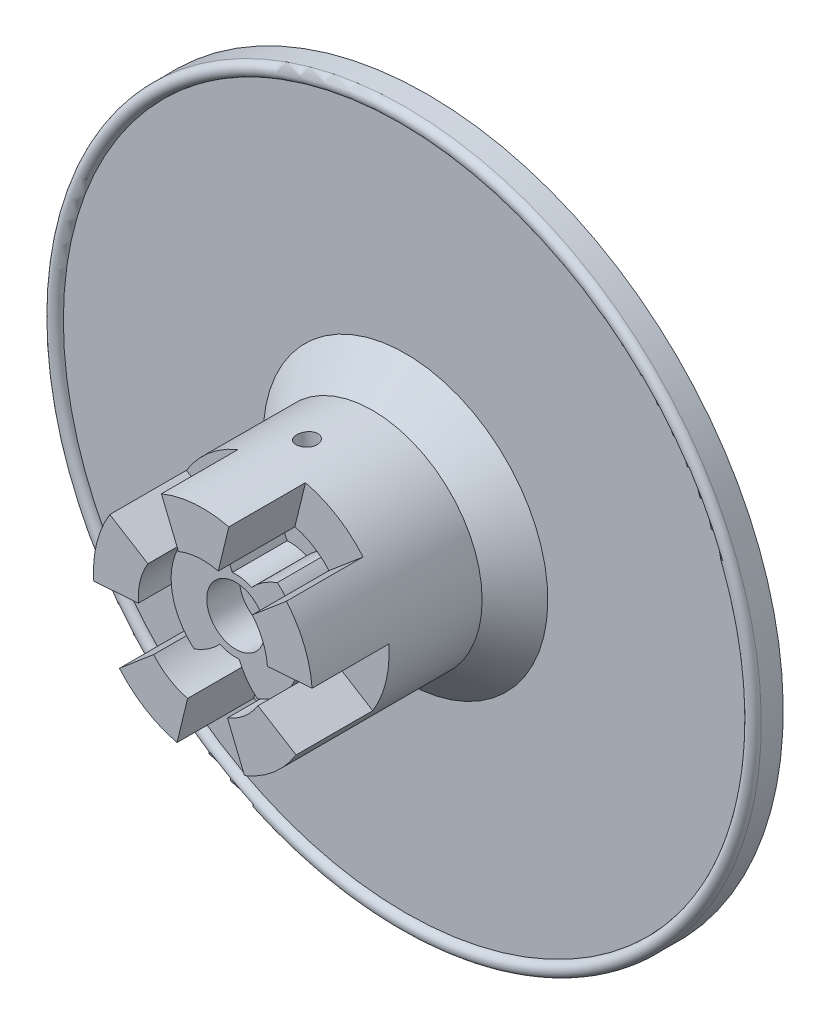
from build123d import *

# Parameters (mm, degrees)
SKETCH11_R                      = 3.3672
CUT_EXTRUDE5_DEPTH              = 3.81
SKETCH11_5_R                    = 3.3672
CUT_EXTRUDE7_DEPTH              = 7.62
CUT_EXTRUDE8_DEPTH              = 10.16
SKETCH13_R                      = 6.35
CUT_EXTRUDE10_DEPTH             = 12.192
CHAMFER1_SIZE                   = 3.81
CHAMFER2_SIZE                   = 3.81
CUT_EXTRUDE11_DEPTH             = 8.89
F_3_32_0_09375_DIAMETER_HOLE1_D = 2.38125


with BuildPart() as part:
    # Sketch2 → Revolve1 (revolve)
    with BuildSketch(Plane(origin=(0, 0, 0), x_dir=(0, 0, -1), z_dir=(1, 0, 0))):
        Polygon((-13.0175, 0), (-13.0175, 9.525), (-13.0175, 12.7), (-9.8425, 12.7), (10.4775, 12.7), (10.4775, 41.275), (13.0175, 41.275), (13.0175, 0), align=None)
    revolve(axis=Axis((0, 0, -13.0175), (0, 0, 1)))

    # Sketch11 → Cut-Extrude5 (cut)
    with BuildSketch(Plane.XY.offset(13.0175)):
        with BuildLine():
            ThreePointArc((-4.819494332, -5.746518457), (-1.340267005, -7.379273972), (2.490906416, -7.074276304))
            ThreePointArc((2.490906416, -7.074276304), (1.265901972, -5.744591723), (0.392647765, -4.16151748))
            ThreePointArc((0.392647765, -4.16151748), (-0.746975478, -4.11271536), (-1.830973459, -3.757650355))
            ThreePointArc((-1.830973459, -3.757650355), (-3.205144168, -4.932534109), (-4.819494332, -5.746518457))
        make_face()
        with BuildLine():
            ThreePointArc((7.5, 0), (6.796918695, 3.17047256), (4.819494332, 5.746518457))
            ThreePointArc((4.819494332, 5.746518457), (3.205144168, 4.932534109), (1.830973459, 3.757650355))
            ThreePointArc((1.830973459, 3.757650355), (0.746975478, 4.11271536), (-0.392647765, 4.16151748))
            ThreePointArc((-0.392647765, 4.16151748), (-1.265901972, 5.744591723), (-2.490906416, 7.074276304))
            ThreePointArc((-2.490906416, 7.074276304), (-7.379273972, 1.340267005), (-4.819494332, -5.746518457))
            ThreePointArc((-4.819494332, -5.746518457), (-3.205144168, -4.932534109), (-1.830973459, -3.757650355))
            ThreePointArc((-1.830973459, -3.757650355), (-0.746975478, -4.11271536), (0.392647765, -4.16151748))
            ThreePointArc((0.392647765, -4.16151748), (1.265901972, -5.744591723), (2.490906416, -7.074276304))
            ThreePointArc((2.490906416, -7.074276304), (6.120939394, -4.334062868), (7.5, 0))
        make_face()
        Circle(SKETCH11_R, mode=Mode.SUBTRACT)
        Circle(SKETCH11_R)
        with BuildLine():
            ThreePointArc((1.830973459, 3.757650355), (3.205144168, 4.932534109), (4.819494332, 5.746518457))
            ThreePointArc((4.819494332, 5.746518457), (1.340267005, 7.379273972), (-2.490906416, 7.074276304))
            ThreePointArc((-2.490906416, 7.074276304), (-1.265901972, 5.744591723), (-0.392647765, 4.16151748))
            ThreePointArc((-0.392647765, 4.16151748), (0.746975478, 4.11271536), (1.830973459, 3.757650355))
        make_face()
    extrude(amount=-CUT_EXTRUDE5_DEPTH, mode=Mode.SUBTRACT)

    # Sketch11_5 → Cut-Extrude7 (cut)
    with BuildSketch(Plane.XY.offset(13.0175)):
        Circle(SKETCH11_5_R)
    extrude(amount=-CUT_EXTRUDE7_DEPTH, mode=Mode.SUBTRACT)

    # Sketch11_6 → Cut-Extrude8 (cut)
    with BuildSketch(Plane.XY.offset(13.0175)):
        with BuildLine():
            ThreePointArc((-4.819494332, -5.746518457), (-1.340267005, -7.379273972), (2.490906416, -7.074276304))
            ThreePointArc((2.490906416, -7.074276304), (1.265901972, -5.744591723), (0.392647765, -4.16151748))
            ThreePointArc((0.392647765, -4.16151748), (-0.746975478, -4.11271536), (-1.830973459, -3.757650355))
            ThreePointArc((-1.830973459, -3.757650355), (-3.205144168, -4.932534109), (-4.819494332, -5.746518457))
        make_face()
        with BuildLine():
            ThreePointArc((1.830973459, 3.757650355), (3.205144168, 4.932534109), (4.819494332, 5.746518457))
            ThreePointArc((4.819494332, 5.746518457), (1.340267005, 7.379273972), (-2.490906416, 7.074276304))
            ThreePointArc((-2.490906416, 7.074276304), (-1.265901972, 5.744591723), (-0.392647765, 4.16151748))
            ThreePointArc((-0.392647765, 4.16151748), (0.746975478, 4.11271536), (1.830973459, 3.757650355))
        make_face()
    extrude(amount=-CUT_EXTRUDE8_DEPTH, mode=Mode.SUBTRACT)

    # Sketch13 → Cut-Extrude10 (cut)
    with BuildSketch(Plane(origin=(0, 0, -13.0175), x_dir=(-1, 0, 0), z_dir=(0, 0, -1))):
        Circle(SKETCH13_R)
    extrude(amount=-CUT_EXTRUDE10_DEPTH, mode=Mode.SUBTRACT)

    # Chamfer1
    chamfer1_edges = [part.edges().sort_by_distance(p)[0] for p in [
        (6.35, 0, -0.8255),
    ]]
    chamfer(chamfer1_edges, length=CHAMFER1_SIZE)

    # Chamfer2
    chamfer2_edges = [part.edges().sort_by_distance(p)[0] for p in [
        (0, -12.7, -10.4775),
    ]]
    chamfer(chamfer2_edges, length=CHAMFER2_SIZE)

    # Sketch14 → Cut-Extrude11 (cut)
    with BuildSketch(Plane.XY.offset(13.0175)):
        with BuildLine():
            Line((-7.478864421, -0.562660625), (-12.664210419, -0.952771992))
            ThreePointArc((-12.664210419, -0.952771992), (-11.749957105, -4.819596251), (-9.685536123, -8.214644849))
            Line((-9.685536123, -8.214644849), (-5.719804797, -4.851168218))
            ThreePointArc((-5.719804797, -4.851168218), (-6.938951046, -2.846218259), (-7.478864421, -0.562660625))
        make_face()
        with BuildLine():
            ThreePointArc((-4.819596251, 11.749957105), (-8.214644849, 9.685536123), (-10.805586775, 6.673027383))
            Line((-10.805586775, 6.673027383), (-6.381252032, 3.940764202))
            ThreePointArc((-6.381252032, 3.940764202), (-4.851168218, 5.719804797), (-2.846218259, 6.938951046))
            Line((-2.846218259, 6.938951046), (-4.819596251, 11.749957105))
        make_face()
        with BuildLine():
            ThreePointArc((9.685536123, 8.214644849), (6.673027383, 10.805586775), (3.007316228, 12.33880258))
            Line((3.007316228, 12.33880258), (1.775974151, 7.286694437))
            ThreePointArc((1.775974151, 7.286694437), (3.940764202, 6.381252032), (5.719804797, 4.851168218))
            Line((5.719804797, 4.851168218), (9.685536123, 8.214644849))
        make_face()
        with BuildLine():
            Line((6.381252032, -3.940764202), (10.805586775, -6.673027383))
            ThreePointArc((10.805586775, -6.673027383), (12.21722047, -3.468360417), (12.7, 0))
            ThreePointArc((12.7, 0), (12.691049451, 0.476721974), (12.664210419, 0.952771992))
            Line((12.664210419, 0.952771992), (7.478864421, 0.562660625))
            ThreePointArc((7.478864421, 0.562660625), (7.494714243, 0.281528725), (7.5, 0))
            ThreePointArc((7.5, 0), (7.214893979, -2.048244341), (6.381252032, -3.940764202))
        make_face()
        with BuildLine():
            Line((-1.775974151, -7.286694437), (-3.007316228, -12.33880258))
            ThreePointArc((-3.007316228, -12.33880258), (0.952771992, -12.664210419), (4.819596251, -11.749957105))
            Line((4.819596251, -11.749957105), (2.846218259, -6.938951046))
            ThreePointArc((2.846218259, -6.938951046), (0.562660625, -7.478864421), (-1.775974151, -7.286694437))
        make_face()
    extrude(amount=-CUT_EXTRUDE11_DEPTH, mode=Mode.SUBTRACT)

    # 3_32 _0.09375_ Diameter Hole1 (through all)
    with Locations(Plane(origin=(1.382526007, -18.376485052, 0), x_dir=(-0.997181923, -0.075021417, 0), z_dir=(0.075021417, -0.997181923, 0))):
        with Locations((0, 0)):
            Hole(F_3_32_0_09375_DIAMETER_HOLE1_D / 2)

    # Sketch17 → Revolve2 (revolve)
    with BuildSketch(Plane(origin=(0, 0, 0), x_dir=(1, 0, 0), z_dir=(0, 1, 0))):
        with BuildLine():
            Line((-41.275, 10.4775), (-39.6875, 10.4775))
            ThreePointArc((-39.6875, 10.4775), (-40.48125, 9.68375), (-41.275, 10.4775))
        make_face()
    revolve(axis=Axis((0, 0, -15.01775), (0, 0, 1)))


solid = part.part
